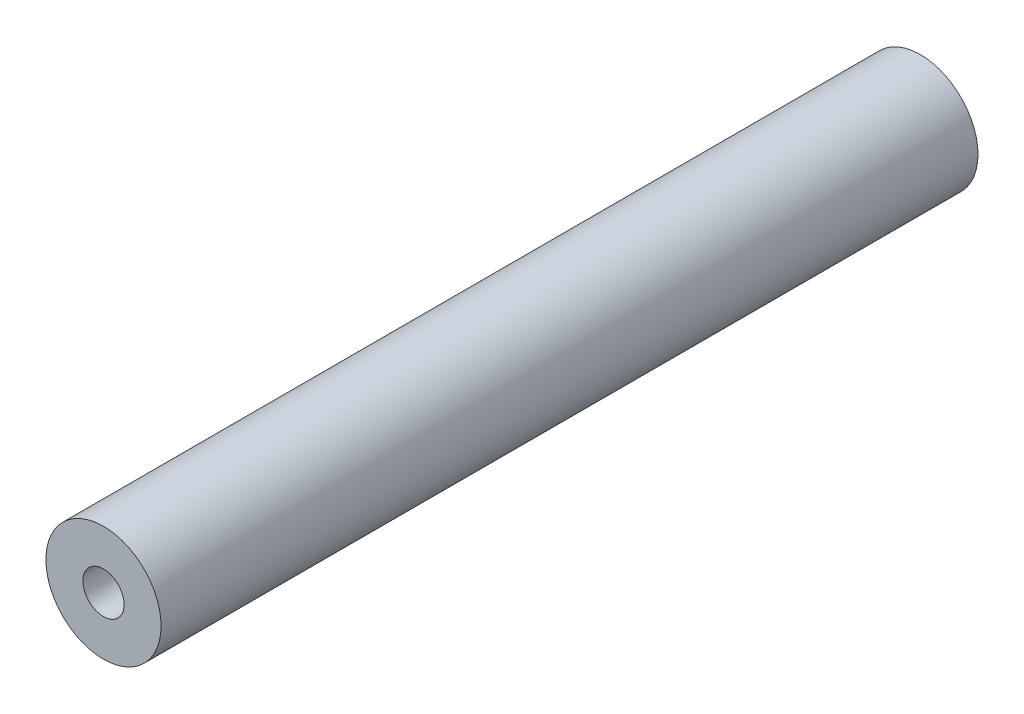
from build123d import *

# Parameters (mm, degrees)
SKETCH1_R           = 4.826
SKETCH1_R_2         = 1.7272
BOSS_EXTRUDE1_DEPTH = 68.453


with BuildPart() as part:
    # Sketch1 → Boss-Extrude1 (new body)
    with BuildSketch(Plane.XY):
        Circle(SKETCH1_R)
        Circle(SKETCH1_R_2, mode=Mode.SUBTRACT)
    extrude(amount=BOSS_EXTRUDE1_DEPTH)


solid = part.part
